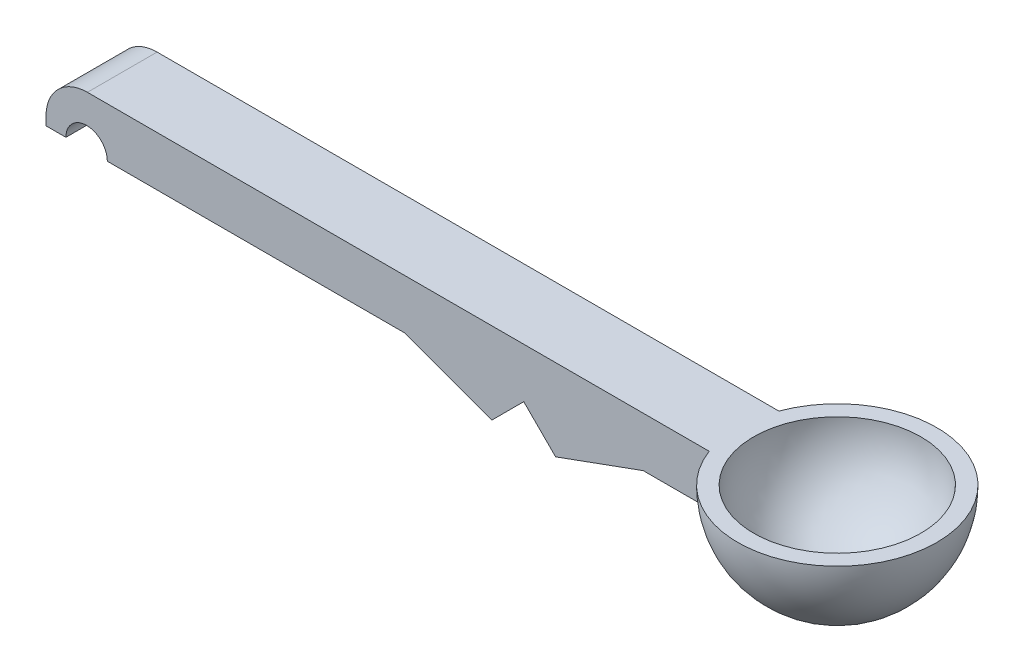
from build123d import *

# Parameters (mm, degrees)
SKETCH1_W               = 107.95
SKETCH1_H               = 11.1125
BOSS_EXTRUDE1_DEPTH     = 7.9375
CUT_EXTRUDE1_DEPTH      = 1
CUT_EXTRUDE1_DEPTH_BACK = 12.1125
BOSS_EXTRUDE2_DEPTH     = 11.1125
FILLET1_R               = 6.604
REVOLVE1_ANGLE          = 180


with BuildPart() as part:
    # Sketch1 → Boss-Extrude1 (new body)
    with BuildSketch(Plane(origin=(0, 0, 0), x_dir=(1, 0, 0), z_dir=(0, 1, 0))):
        with Locations((53.975, 5.55625)):
            Rectangle(SKETCH1_W, SKETCH1_H)
    extrude(amount=BOSS_EXTRUDE1_DEPTH)

    # Sketch2 → Cut-Extrude1 (cut, two sides)
    with BuildSketch(Plane.XY) as cut_extrude1_sk:
        with BuildLine():
            Line((3.175, 0), (9.779, 0))
            ThreePointArc((9.779, 0), (6.477, 3.302), (3.175, 0))
        make_face()
    extrude(amount=CUT_EXTRUDE1_DEPTH, mode=Mode.SUBTRACT)
    extrude(cut_extrude1_sk.sketch, amount=-CUT_EXTRUDE1_DEPTH_BACK, mode=Mode.SUBTRACT)

    # Sketch2_4 → Boss-Extrude2 (add, through all)
    with BuildSketch(Plane.XY):
        Polygon((76.2, 0), (57.15, 0), (71.12, -5.08), align=None)
        Polygon((95.25, 0), (76.2, 0), (81.28, -5.08), align=None)
    extrude(amount=-BOSS_EXTRUDE2_DEPTH)

    # Fillet1
    fillet1_edges = [part.edges().sort_by_distance(p)[0] for p in [
        (0, 7.9375, -5.55625),
    ]]
    fillet(fillet1_edges, radius=FILLET1_R)

    # Sketch3 → Revolve1 (revolve)
    with BuildSketch(Plane(origin=(0, 7.9375, 0), x_dir=(1, 0, 0), z_dir=(0, 1, 0))):
        with BuildLine():
            Line((104.775, 5.55625), (136.525, 5.55625))
            ThreePointArc((136.525, 5.55625), (120.65, -10.31875), (104.775, 5.55625))
        make_face()
    revolve(axis=Axis((104.775, 7.9375, -5.55625), (1, 0, 0)), revolution_arc=REVOLVE1_ANGLE)

    # Sketch5 → Cut-Revolve2 (revolve, cut)
    with BuildSketch(Plane(origin=(0, 7.9375, 0), x_dir=(1, 0, 0), z_dir=(0, 1, 0))):
        with BuildLine():
            Line((107.315, 5.55625), (133.985, 5.55625))
            ThreePointArc((133.985, 5.55625), (120.65, -7.77875), (107.315, 5.55625))
        make_face()
    revolve(axis=Axis((107.315, 7.9375, -5.55625), (1, 0, 0)), mode=Mode.SUBTRACT)

    # Sketch6 → Cut-Revolve3 (revolve, cut)
    with BuildSketch(Plane.XY.offset(-5.55625)):
        Polygon((16.129, 0), (19.304, 0), (19.304, 3.175), (19.685, 3.175), (19.685, 4.953), (16.129, 4.953), (16.129, 3.175), align=None)
    revolve(axis=Axis((16.129, 0, -5.55625), (0, 1, 0)), mode=Mode.SUBTRACT)


solid = part.part
